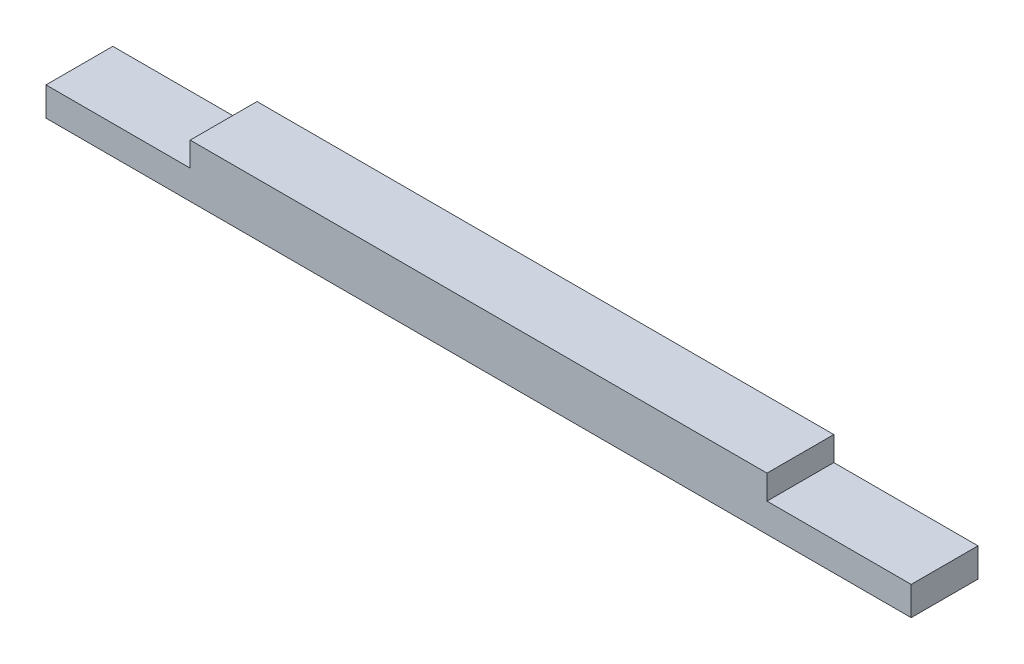
from build123d import *

# Parameters (mm, degrees)
BOSS_EXTRUDE1_DEPTH = 6.95


with BuildPart() as part:
    # Sketch1 → Boss-Extrude1 (new body)
    with BuildSketch(Plane.XY):
        Polygon((-7.5, 0), (82.5, 0), (82.5, 3), (67.5, 3), (67.5, 5.525), (7.5, 5.525), (7.5, 3), (-7.5, 3), align=None)
    extrude(amount=BOSS_EXTRUDE1_DEPTH)


solid = part.part
